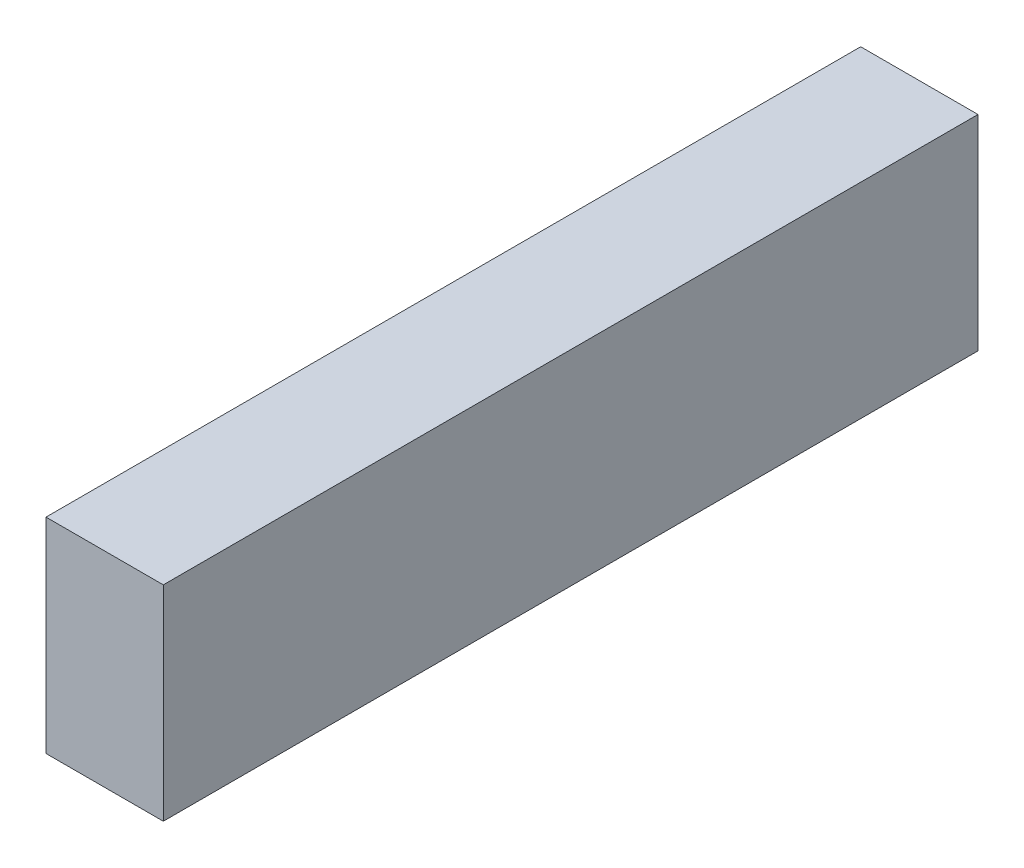
from build123d import *

# Parameters (mm, degrees)
SCHIZZO1_W                   = 7.2
SCHIZZO1_H                   = 12.566
ESTRUSIONE_ESTRUSIONE1_DEPTH = 50


with BuildPart() as part:
    # Schizzo1 → Estrusione-Estrusione1 (new body)
    with BuildSketch(Plane.XY):
        with Locations((3.6, 6.283)):
            Rectangle(SCHIZZO1_W, SCHIZZO1_H)
    extrude(amount=ESTRUSIONE_ESTRUSIONE1_DEPTH)


solid = part.part
